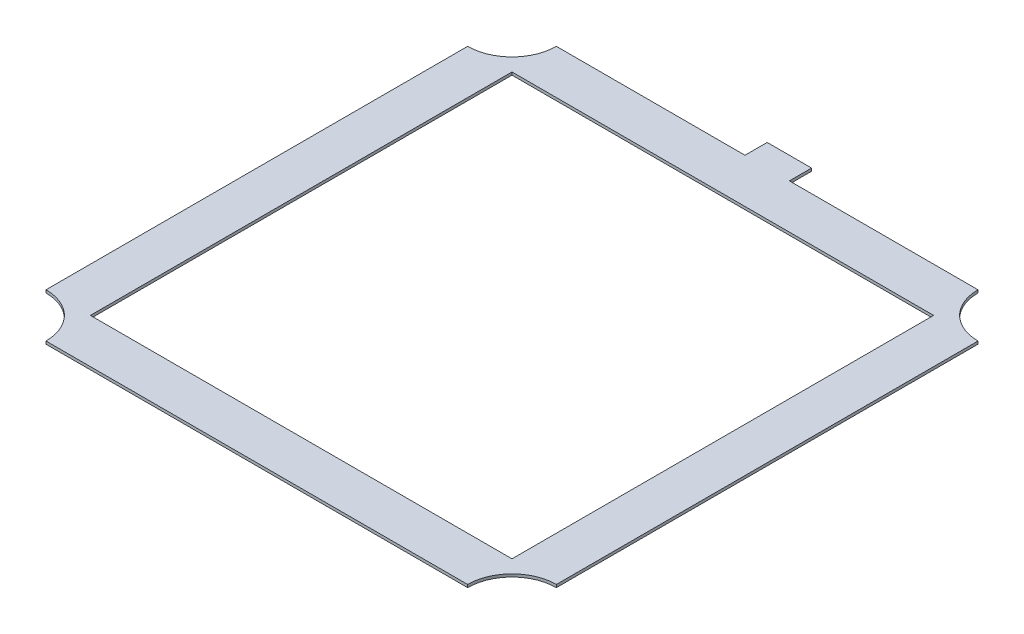
from build123d import *

# Parameters (mm, degrees)
SKETCH1_W           = 120.65
SKETCH1_H           = 120.65
BOSS_EXTRUDE1_DEPTH = 0.8
SKETCH2_W           = 12.7
SKETCH2_H           = 6.35
BOSS_EXTRUDE2_DEPTH = 0.8


with BuildPart() as part:
    # Sketch1 → Boss-Extrude1 (new body)
    with BuildSketch(Plane(origin=(0, 0, 0), x_dir=(1, 0, 0), z_dir=(0, 1, 0))):
        with BuildLine():
            Line((69.867533733, 87.286057649), (-50.782466267, 87.286057649))
            ThreePointArc((-50.782466267, 87.286057649), (-54.502210146, 78.305801528), (-63.482466267, 74.586057649))
            Line((-63.482466267, 74.586057649), (-63.482466267, -46.063942351))
            ThreePointArc((-63.482466267, -46.063942351), (-54.502210146, -49.78368623), (-50.782466267, -58.763942351))
            Line((-50.782466267, -58.763942351), (69.867533733, -58.763942351))
            ThreePointArc((69.867533733, -58.763942351), (73.587277612, -49.78368623), (82.567533733, -46.063942351))
            Line((82.567533733, -46.063942351), (82.567533733, 74.586057649))
            ThreePointArc((82.567533733, 74.586057649), (73.587277612, 78.305801528), (69.867533733, 87.286057649))
        make_face()
        with Locations((9.542533733, 14.261057649)):
            Rectangle(SKETCH1_W, SKETCH1_H, mode=Mode.SUBTRACT)
    extrude(amount=BOSS_EXTRUDE1_DEPTH)

    # Sketch2 → Boss-Extrude2 (add)
    with BuildSketch(Plane(origin=(0, 0.8, 0), x_dir=(1, 0, 0), z_dir=(0, 1, 0))):
        with Locations((9.542533733, 90.461057649)):
            Rectangle(SKETCH2_W, SKETCH2_H)
    extrude(amount=-BOSS_EXTRUDE2_DEPTH)


solid = part.part
